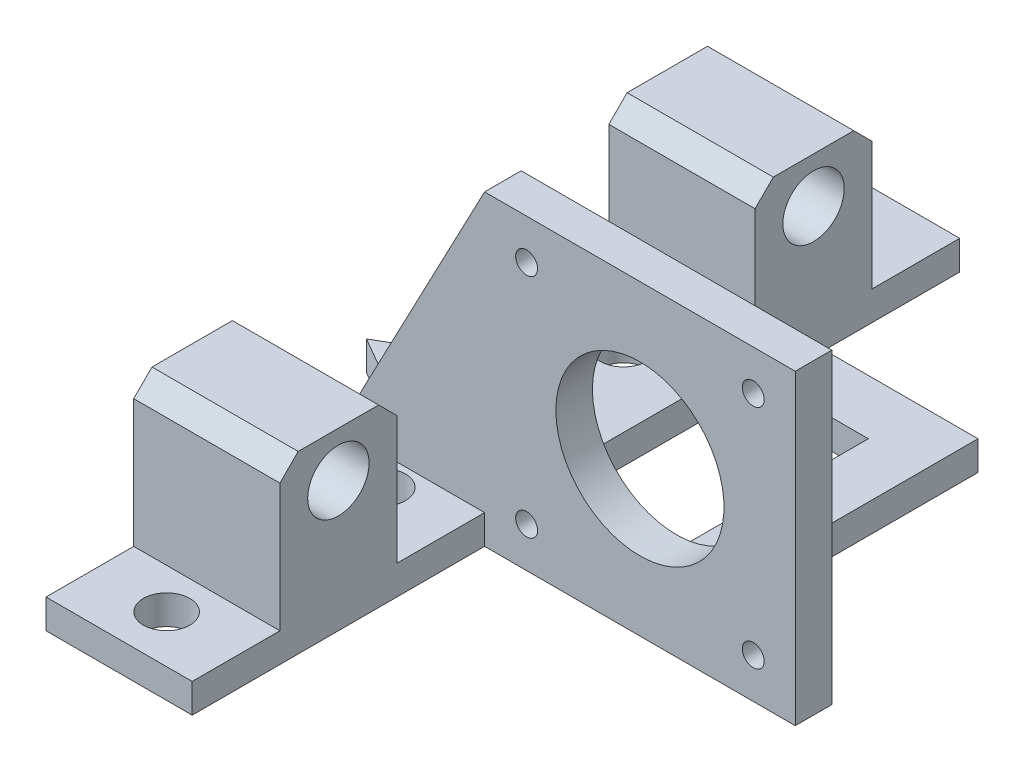
from build123d import *

# Parameters (mm, degrees)
SKETCH1_W           = 20
SKETCH1_H           = 105
BOSS_EXTRUDE1_DEPTH = 4
SKETCH2_R           = 4.2
BOSS_EXTRUDE2_DEPTH = 20
BOSS_EXTRUDE3_DEPTH = 4
SKETCH4_R           = 3.175
CUT_EXTRUDE1_DEPTH  = 5
SKETCH5_W           = 5
SKETCH5_H           = 42
BOSS_EXTRUDE4_DEPTH = 42.5
SKETCH6_R           = 11.5
SKETCH6_R_2         = 1.5
CUT_EXTRUDE2_DEPTH  = 46
BOSS_EXTRUDE5_DEPTH = 5
BOSS_EXTRUDE6_DEPTH = 4


with BuildPart() as part:
    # Sketch1 → Boss-Extrude1 (new body)
    with BuildSketch(Plane(origin=(0, 0, 0), x_dir=(1, 0, 0), z_dir=(0, 1, 0))):
        with Locations((10, 52.5)):
            Rectangle(SKETCH1_W, SKETCH1_H)
    extrude(amount=BOSS_EXTRUDE1_DEPTH)

    # Sketch2 → Boss-Extrude2 (add)
    with BuildSketch(Plane.ZY):
        Polygon((-12, 4), (-12, 21.5), (-14.5, 24), (-25.5, 24), (-28, 21.5), (-28, 4), align=None)
        with Locations((-20, 17.8)):
            Circle(SKETCH2_R, mode=Mode.SUBTRACT)
        Polygon((-93, 4), (-77, 4), (-77, 21.5), (-79.5, 24), (-90.5, 24), (-93, 21.5), align=None)
        with Locations((-85, 17.8)):
            Circle(SKETCH2_R, mode=Mode.SUBTRACT)
    extrude(amount=-BOSS_EXTRUDE2_DEPTH)

    # Sketch3 → Boss-Extrude3 (add)
    with BuildSketch(Plane.XZ):
        Polygon((0, -57.5), (-8.660254038, -52.5), (0, -47.5), align=None)
    extrude(amount=-BOSS_EXTRUDE3_DEPTH)

    # Sketch4 → Cut-Extrude1 (cut, through all)
    with BuildSketch(Plane(origin=(0, 4, 0), x_dir=(1, 0, 0), z_dir=(0, 1, 0))):
        with Locations((10, 98.5)):
            Circle(SKETCH4_R)
        with Locations((10, 69)):
            Circle(SKETCH4_R)
        with Locations((10, 36)):
            Circle(SKETCH4_R)
        with Locations((10, 6.5)):
            Circle(SKETCH4_R)
    extrude(amount=-CUT_EXTRUDE1_DEPTH, mode=Mode.SUBTRACT)

    # Sketch5 → Boss-Extrude4 (add)
    with BuildSketch(Plane(origin=(20, 0, 0), x_dir=(0, 0, -1), z_dir=(1, 0, 0))):
        with Locations((42.5, 21)):
            Rectangle(SKETCH5_W, SKETCH5_H)
    extrude(amount=BOSS_EXTRUDE4_DEPTH)

    # Sketch6 → Cut-Extrude2 (cut, through all)
    with BuildSketch(Plane(origin=(0, 0, -45), x_dir=(-1, 0, 0), z_dir=(0, 0, -1))):
        with Locations((-41.25, 21)):
            Circle(SKETCH6_R)
        with Locations((-56.75, 36.5)):
            Circle(SKETCH6_R_2)
        with Locations((-25.75, 36.5)):
            Circle(SKETCH6_R_2)
        with Locations((-25.75, 5.5)):
            Circle(SKETCH6_R_2)
        with Locations((-56.75, 5.5)):
            Circle(SKETCH6_R_2)
    extrude(amount=-CUT_EXTRUDE2_DEPTH, mode=Mode.SUBTRACT)

    # Sketch7 → Boss-Extrude5 (add)
    with BuildSketch(Plane.XY.offset(-40)):
        Polygon((20, 42), (0, 4), (20, 4), align=None)
    extrude(amount=-BOSS_EXTRUDE5_DEPTH)

    # Sketch8 → Boss-Extrude6 (add)
    with BuildSketch(Plane.XZ):
        Polygon((45, -45), (45, -82.5), (20, -82.5), (20, -75), (37.5, -75), (37.5, -45), align=None)
    extrude(amount=-BOSS_EXTRUDE6_DEPTH)


solid = part.part
